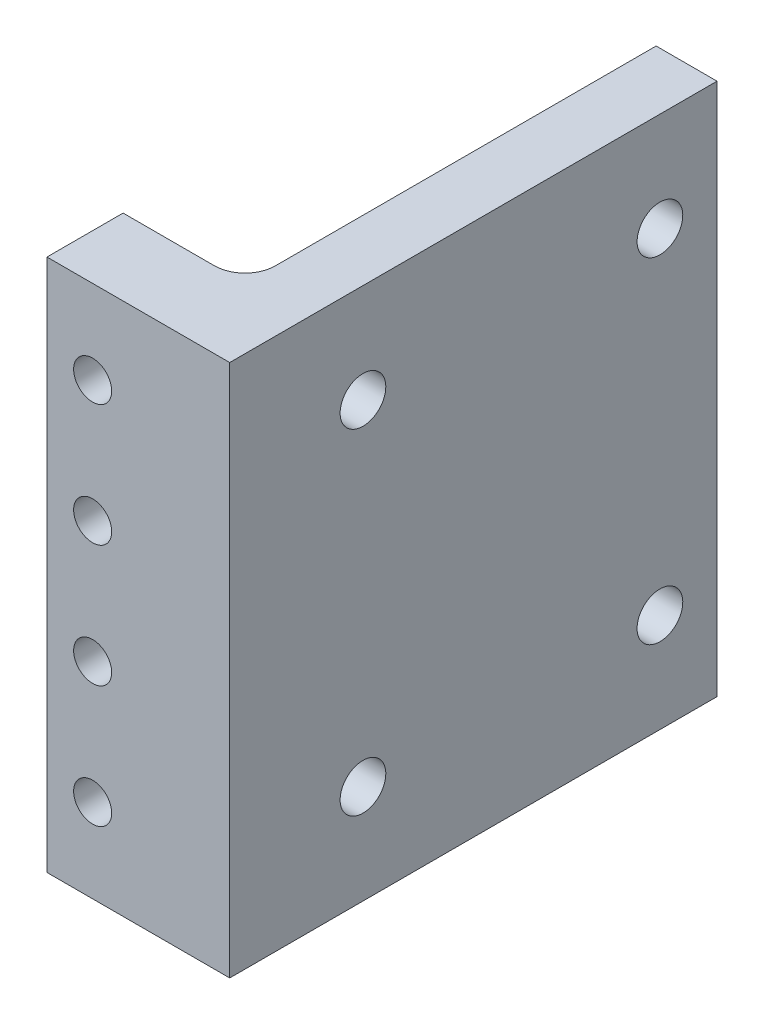
from build123d import *

# Parameters (mm, degrees)
ESQUISSE1_W             = 12
ESQUISSE1_H             = 35
BOSS_EXTRU_1_DEPTH      = 5
ESQUISSE2_W             = 4
ESQUISSE2_H             = 35
BOSS_EXTRU_2_DEPTH      = 27
ESQUISSE3_R             = 1.25
ENL_V_MAT_EXTRU_1_DEPTH = 33
ESQUISSE4_R             = 1.5
ENL_V_MAT_EXTRU_2_DEPTH = 5
CONG_1_R                = 2


with BuildPart() as part:
    # Esquisse1 → Boss.-Extru.1 (new body)
    with BuildSketch(Plane.XY):
        with Locations((6, 17.5)):
            Rectangle(ESQUISSE1_W, ESQUISSE1_H)
    extrude(amount=BOSS_EXTRU_1_DEPTH)

    # Esquisse2 → Boss.-Extru.2 (add)
    with BuildSketch(Plane(origin=(0, 0, 0), x_dir=(-1, 0, 0), z_dir=(0, 0, -1))):
        with Locations((-10, 17.5)):
            Rectangle(ESQUISSE2_W, ESQUISSE2_H)
    extrude(amount=BOSS_EXTRU_2_DEPTH)

    # Esquisse3 → Enlèv. mat.-Extru.1 (cut, through all)
    with BuildSketch(Plane.XY.offset(5)):
        with Locations((3, 5.5)):
            Circle(ESQUISSE3_R)
        with Locations((3, 13.5)):
            Circle(ESQUISSE3_R)
        with Locations((3, 21.5)):
            Circle(ESQUISSE3_R)
        with Locations((3, 29.5)):
            Circle(ESQUISSE3_R)
    extrude(amount=-ENL_V_MAT_EXTRU_1_DEPTH, mode=Mode.SUBTRACT)

    # Esquisse4 → Enlèv. mat.-Extru.2 (cut, through all)
    with BuildSketch(Plane.ZY.offset(-8)):
        with Locations((-23.25, 28.5)):
            Circle(ESQUISSE4_R)
        with Locations((-3.75, 28.5)):
            Circle(ESQUISSE4_R)
        with Locations((-23.25, 6.5)):
            Circle(ESQUISSE4_R)
        with Locations((-3.75, 6.5)):
            Circle(ESQUISSE4_R)
    extrude(amount=-ENL_V_MAT_EXTRU_2_DEPTH, mode=Mode.SUBTRACT)

    # Congé1
    cong_1_edges = [part.edges().sort_by_distance(p)[0] for p in [
        (8, 17.5, 0),
    ]]
    fillet(cong_1_edges, radius=CONG_1_R)


solid = part.part
